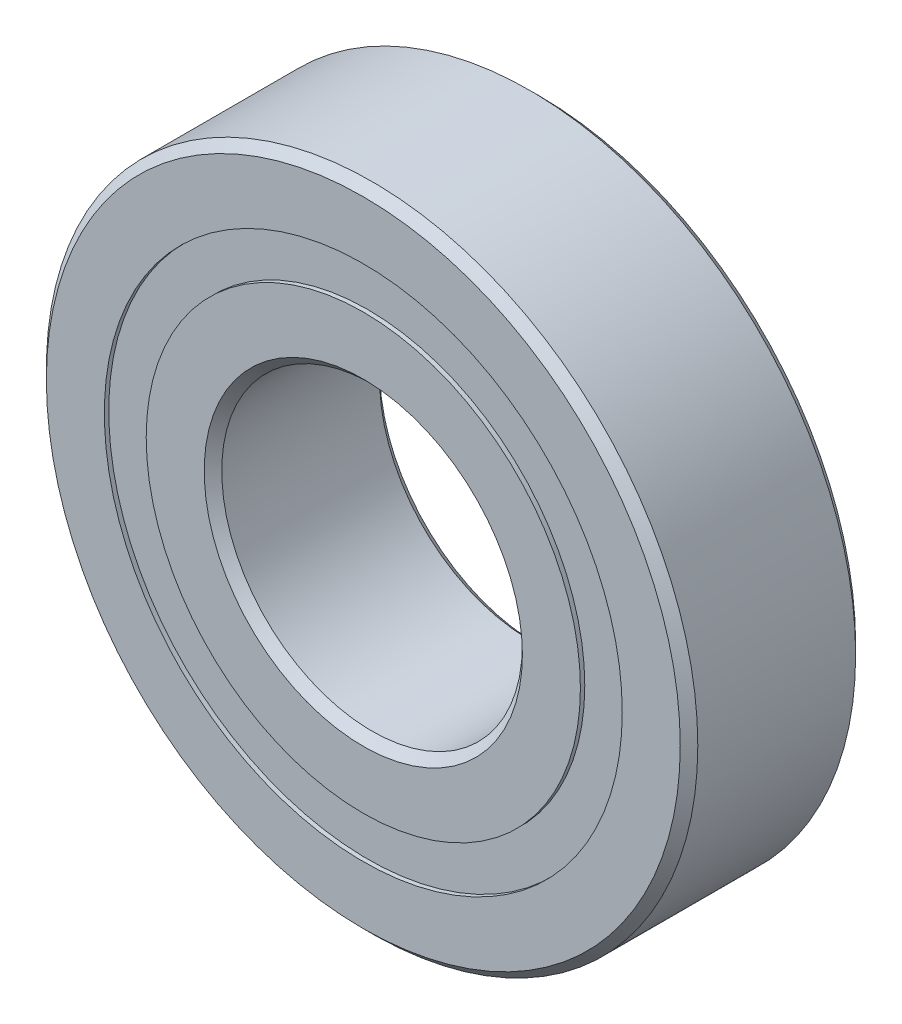
from build123d import *

# Parameters (mm, degrees)
CIRPATTERN1_COUNT = 10
SKETCH5_W         = 2.475587948
SKETCH5_H         = 2.651648352


with BuildPart() as part:
    # Sketch1 → Revolve1 (revolve)
    with BuildSketch(Plane(origin=(0, 0, 0), x_dir=(0, 0, -1), z_dir=(1, 0, 0))):
        with BuildLine():
            Line((5.000625, 20.6375), (-5.000625, 20.6375))
            Line((-5.000625, 20.6375), (-5.55625, 20.081875))
            Line((-5.55625, 20.081875), (-5.55625, 16.407074176))
            Line((-5.55625, 16.407074176), (-2.469444444, 16.407074176))
            ThreePointArc((-2.469444444, 16.407074176), (0, 17.884099552), (2.469444444, 16.407074176))
            Line((2.469444444, 16.407074176), (5.55625, 16.407074176))
            Line((5.55625, 16.407074176), (5.55625, 20.081875))
            Line((5.55625, 20.081875), (5.000625, 20.6375))
        make_face()
    revolve(axis=Axis((0, 0, 5.55625), (0, 0, -1)))


with BuildPart() as body_2:
    # Sketch3 → Revolve3 (revolve)
    with BuildSketch(Plane(origin=(0, 0, 0), x_dir=(0, 0, -1), z_dir=(1, 0, 0))):
        with BuildLine():
            Line((-5.55625, 13.755425824), (-2.469444444, 13.755425824))
            ThreePointArc((-2.469444444, 13.755425824), (0, 12.278400448), (2.469444444, 13.755425824))
            Line((2.469444444, 13.755425824), (5.55625, 13.755425824))
            Line((5.55625, 13.755425824), (5.55625, 10.080625))
            Line((5.55625, 10.080625), (5.000625, 9.525))
            Line((5.000625, 9.525), (-5.000625, 9.525))
            Line((-5.000625, 9.525), (-5.55625, 10.080625))
            Line((-5.55625, 10.080625), (-5.55625, 13.755425824))
        make_face()
    revolve(axis=Axis((0, 0, 5.55625), (0, 0, -1)))


with BuildPart() as body_3:
    # Sketch4 → Revolve4 (revolve)
    with BuildSketch(Plane(origin=(0, 0, 0), x_dir=(0, 0, -1), z_dir=(1, 0, 0))):
        with BuildLine():
            Line((-2.802849552, 15.08125), (2.802849552, 15.08125))
            ThreePointArc((2.802849552, 15.08125), (0, 17.884099552), (-2.802849552, 15.08125))
        make_face()
    revolve(axis=Axis((0, 15.08125, 2.802849552), (0, 0, -1)))


with BuildPart() as cirpattern1_1:
    # CirPattern1: pattern copy
    add(body_3.part.rotate(Axis((0, 0, -5.55625), (0, 0, 1)), 1 * 360 / CIRPATTERN1_COUNT))


with BuildPart() as cirpattern1_2:
    # CirPattern1: pattern copy
    add(body_3.part.rotate(Axis((0, 0, -5.55625), (0, 0, 1)), 2 * 360 / CIRPATTERN1_COUNT))


with BuildPart() as cirpattern1_3:
    # CirPattern1: pattern copy
    add(body_3.part.rotate(Axis((0, 0, -5.55625), (0, 0, 1)), 3 * 360 / CIRPATTERN1_COUNT))


with BuildPart() as cirpattern1_4:
    # CirPattern1: pattern copy
    add(body_3.part.rotate(Axis((0, 0, -5.55625), (0, 0, 1)), 4 * 360 / CIRPATTERN1_COUNT))


with BuildPart() as cirpattern1_5:
    # CirPattern1: pattern copy
    add(body_3.part.rotate(Axis((0, 0, -5.55625), (0, 0, 1)), 5 * 360 / CIRPATTERN1_COUNT))


with BuildPart() as cirpattern1_6:
    # CirPattern1: pattern copy
    add(body_3.part.rotate(Axis((0, 0, -5.55625), (0, 0, 1)), 6 * 360 / CIRPATTERN1_COUNT))


with BuildPart() as cirpattern1_7:
    # CirPattern1: pattern copy
    add(body_3.part.rotate(Axis((0, 0, -5.55625), (0, 0, 1)), 7 * 360 / CIRPATTERN1_COUNT))


with BuildPart() as cirpattern1_8:
    # CirPattern1: pattern copy
    add(body_3.part.rotate(Axis((0, 0, -5.55625), (0, 0, 1)), 8 * 360 / CIRPATTERN1_COUNT))


with BuildPart() as cirpattern1_9:
    # CirPattern1: pattern copy
    add(body_3.part.rotate(Axis((0, 0, -5.55625), (0, 0, 1)), 9 * 360 / CIRPATTERN1_COUNT))


with BuildPart() as body_13:
    # Sketch5 → Revolve5 (revolve)
    with BuildSketch(Plane(origin=(0, 0, 0), x_dir=(0, 0, -1), z_dir=(1, 0, 0))):
        with Locations((-4.040643526, 15.08125)):
            Rectangle(SKETCH5_W, SKETCH5_H)
        with Locations((4.040643526, 15.08125)):
            Rectangle(SKETCH5_W, SKETCH5_H)
    revolve(axis=Axis((0, 0, 5.55625), (0, 0, -1)))


solid = Compound([part.part, body_2.part, body_3.part, cirpattern1_1.part, cirpattern1_2.part, cirpattern1_3.part, cirpattern1_4.part, cirpattern1_5.part, cirpattern1_6.part, cirpattern1_7.part, cirpattern1_8.part, cirpattern1_9.part, body_13.part])
